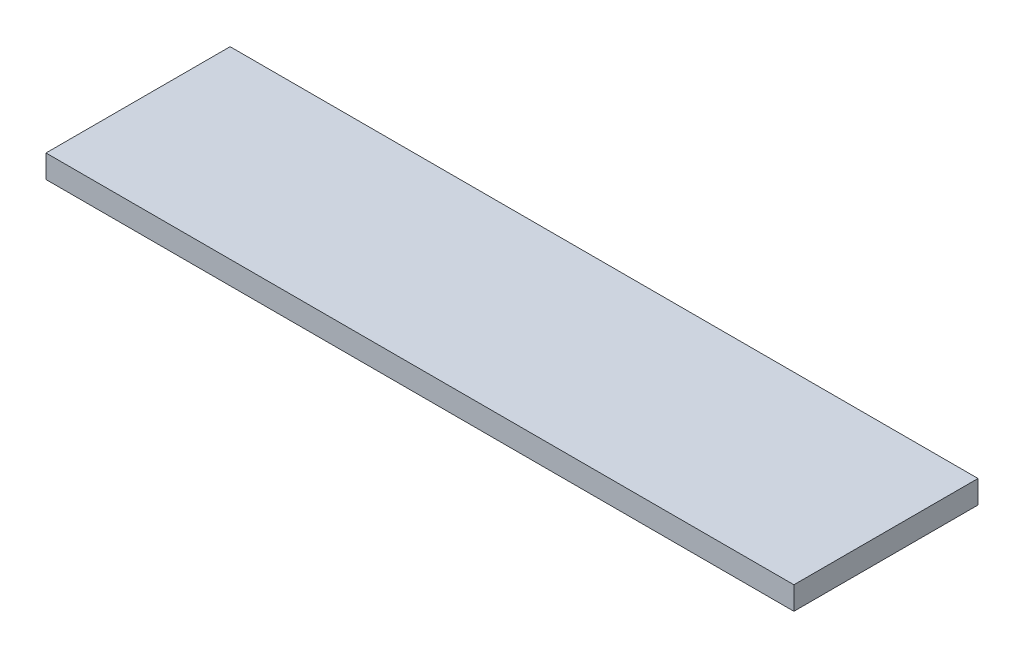
from build123d import *

# Parameters (mm, degrees)
SKIZZE1_W                       = 32.5
SKIZZE1_H                       = 8
AUFSATZ_LINEAR_AUSTRAGEN1_DEPTH = 1


with BuildPart() as part:
    # Skizze1 → Aufsatz-Linear austragen1 (new body)
    with BuildSketch(Plane(origin=(0, 0, 0), x_dir=(1, 0, 0), z_dir=(0, 1, 0))):
        with Locations((16.25, 4)):
            Rectangle(SKIZZE1_W, SKIZZE1_H)
    extrude(amount=AUFSATZ_LINEAR_AUSTRAGEN1_DEPTH)


solid = part.part
